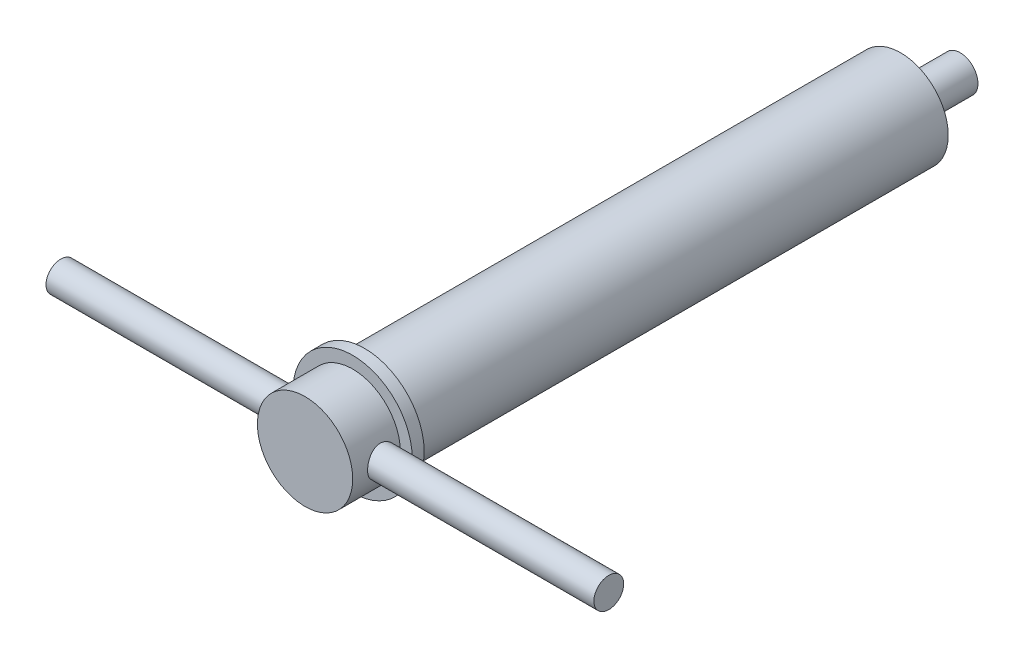
from build123d import *

# Parameters (mm, degrees)
SKETCH1_R           = 4
BOSS_EXTRUDE1_DEPTH = 50
SKETCH2_R           = 5
BOSS_EXTRUDE2_DEPTH = 1
SKETCH3_R           = 1.25
BOSS_EXTRUDE3_DEPTH = 23
SKETCH4_R           = 1.5
BOSS_EXTRUDE4_DEPTH = 5


with BuildPart() as part:
    # Sketch1 → Boss-Extrude1 (new body)
    with BuildSketch(Plane.XY):
        Circle(SKETCH1_R)
    extrude(amount=BOSS_EXTRUDE1_DEPTH)

    # Sketch2 → Boss-Extrude2 (add)
    with BuildSketch(Plane.XY.offset(46)):
        Circle(SKETCH2_R)
    extrude(amount=-BOSS_EXTRUDE2_DEPTH)

    # Sketch3 → Boss-Extrude3 (add, symmetric)
    with BuildSketch(Plane(origin=(0, 0, 0), x_dir=(0, 0, -1), z_dir=(1, 0, 0))):
        with Locations((-47.5, 0)):
            Circle(SKETCH3_R)
    extrude(amount=BOSS_EXTRUDE3_DEPTH, both=True)

    # Sketch4 → Boss-Extrude4 (add)
    with BuildSketch(Plane(origin=(0, 0, 0), x_dir=(-1, 0, 0), z_dir=(0, 0, -1))):
        Circle(SKETCH4_R)
    extrude(amount=BOSS_EXTRUDE4_DEPTH)


solid = part.part
